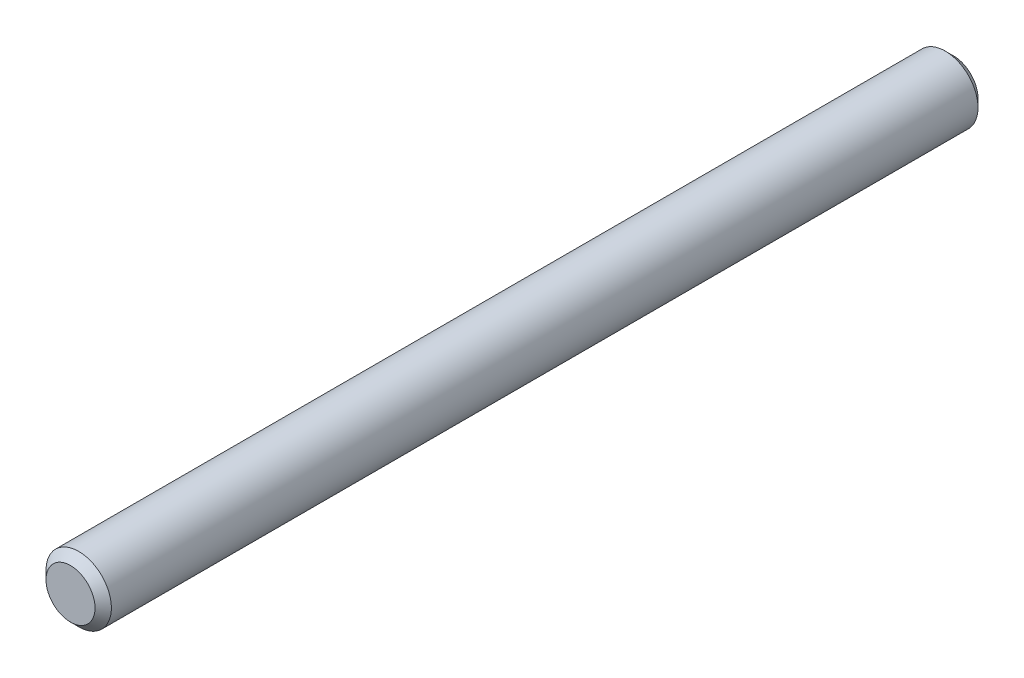
from build123d import *

# Parameters (mm, degrees)
ESQUISSE1_R          = 1
BASE_EXTRUSION_DEPTH = 27
CHANFREIN1_SIZE      = 0.25


with BuildPart() as part:
    # Esquisse1 → Base-Extrusion (new body)
    with BuildSketch(Plane.XY):
        Circle(ESQUISSE1_R)
    extrude(amount=BASE_EXTRUSION_DEPTH)

    # Chanfrein1
    chanfrein1_edges = [part.edges().sort_by_distance(p)[0] for p in [
        (-1, 0, 0),
        (-1, 0, 27),
    ]]
    chamfer(chanfrein1_edges, length=CHANFREIN1_SIZE)


solid = part.part
